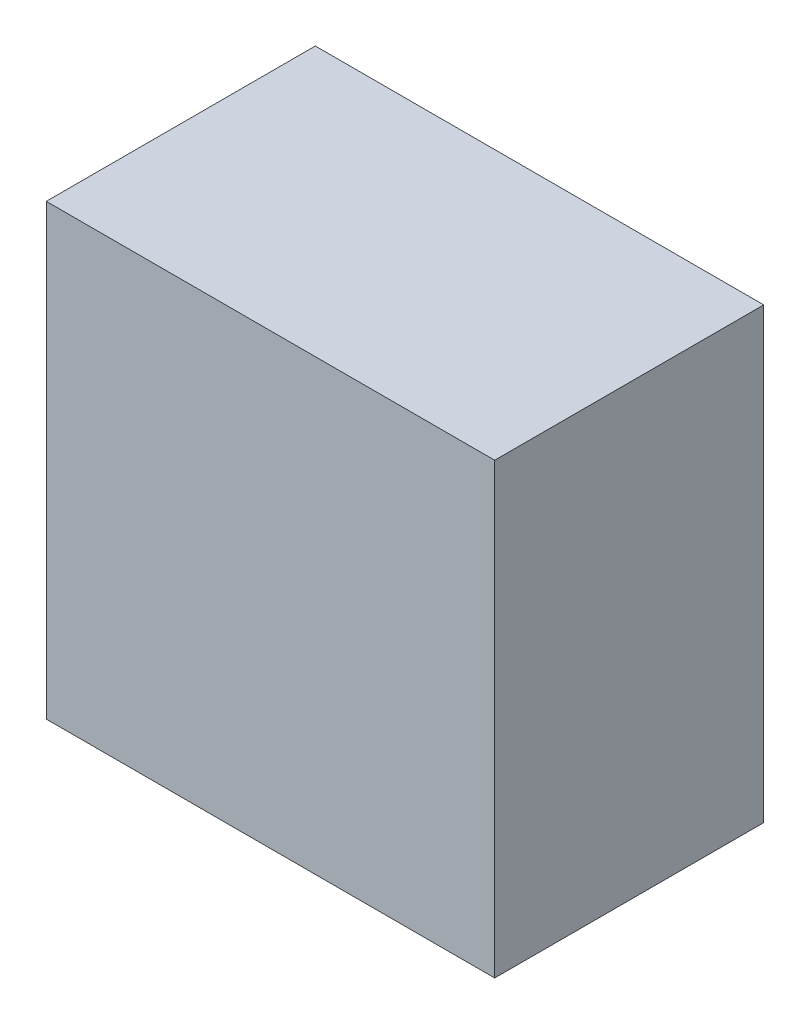
from build123d import *

# Parameters (mm, degrees)
SKETCH2_W           = 50
SKETCH2_H           = 50
BOSS_EXTRUDE2_DEPTH = 30
SKETCH3_W           = 45
SKETCH3_H           = 45
CUT_EXTRUDE1_DEPTH  = 27


with BuildPart() as part:
    # Sketch2 → Boss-Extrude2 (new body)
    with BuildSketch(Plane.XY):
        with Locations((32.80141844, 3.368794326)):
            Rectangle(SKETCH2_W, SKETCH2_H)
    extrude(amount=-BOSS_EXTRUDE2_DEPTH)

    # Sketch3 → Cut-Extrude1 (cut)
    with BuildSketch(Plane(origin=(0, 0, -30), x_dir=(-1, 0, 0), z_dir=(0, 0, -1))):
        with Locations((-32.80141844, 3.368794326)):
            Rectangle(SKETCH3_W, SKETCH3_H)
    extrude(amount=-CUT_EXTRUDE1_DEPTH, mode=Mode.SUBTRACT)


solid = part.part
